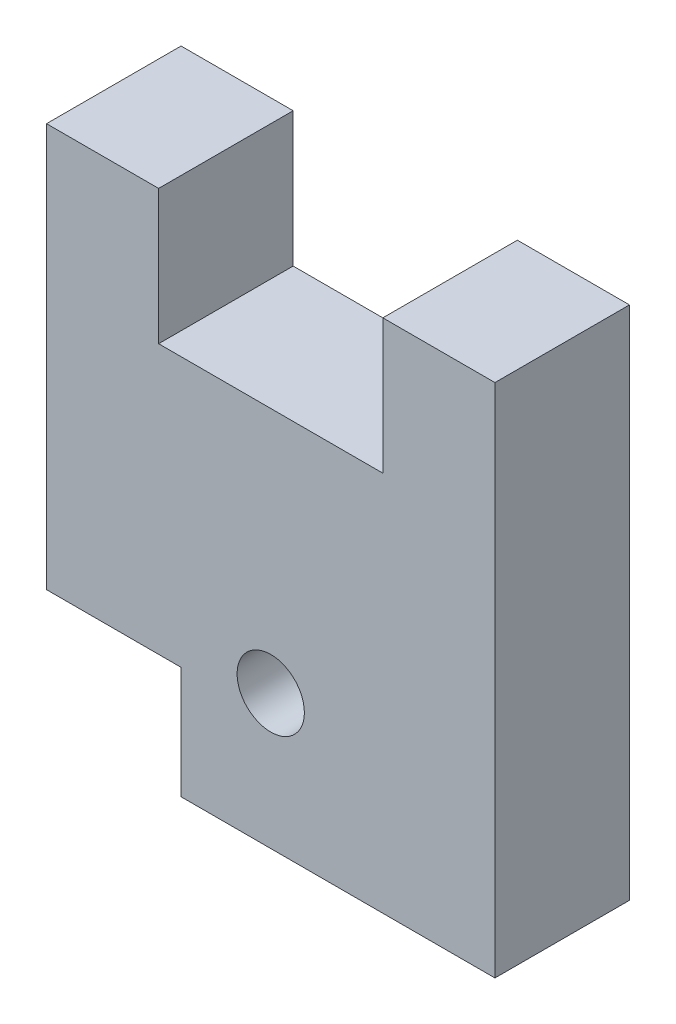
from build123d import *

# Parameters (mm, degrees)
SKETCH1_R           = 1.5
BOSS_EXTRUDE1_DEPTH = 6


with BuildPart() as part:
    # Sketch1 → Boss-Extrude1 (new body)
    with BuildSketch(Plane.XY):
        Polygon((15, 0), (20, 0), (20, -23), (6, -23), (6, -18), (0, -18), (0, 0), (5, 0), (5, -6), (15, -6), align=None)
        with Locations((10, -17)):
            Circle(SKETCH1_R, mode=Mode.SUBTRACT)
    extrude(amount=BOSS_EXTRUDE1_DEPTH)


solid = part.part
